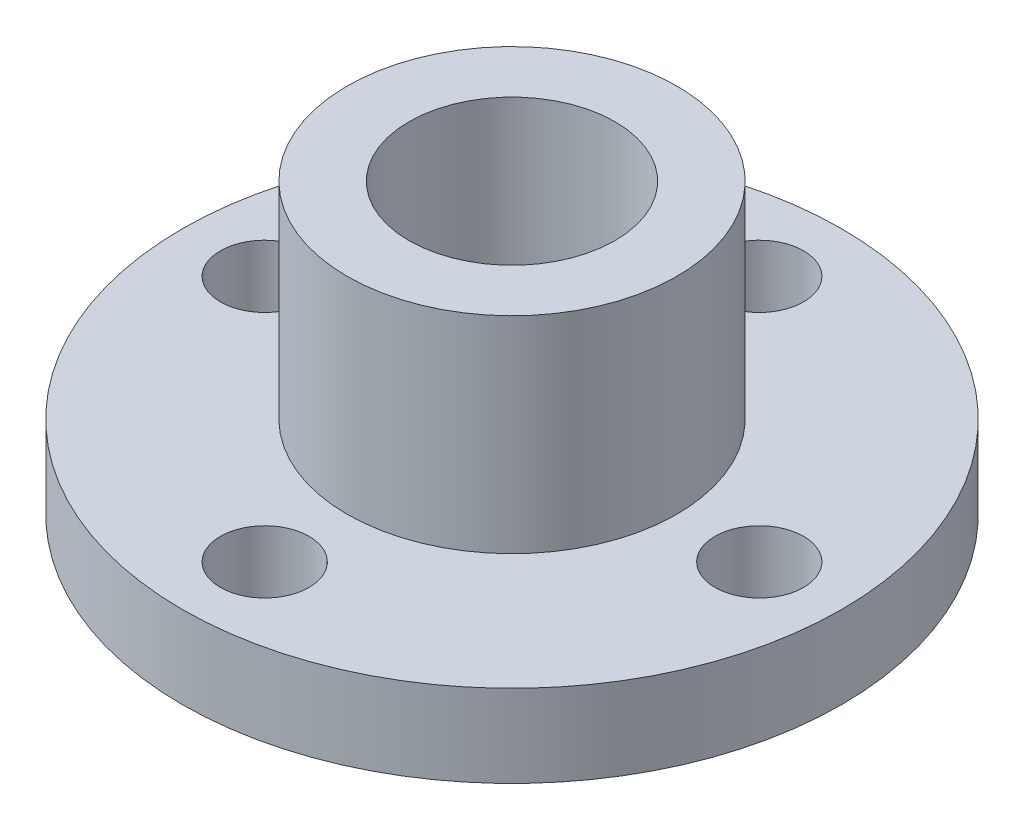
from build123d import *

# Parameters (mm, degrees)
SKETCH2_R          = 2.15
CUT_EXTRUDE1_DEPTH = 5
CIRPATTERN1_COUNT  = 4


with BuildPart() as part:
    # Sketch1 → Revolve4 (revolve)
    with BuildSketch(Plane(origin=(0, 0, 0), x_dir=(0, 0, -1), z_dir=(1, 0, 0))):
        Polygon((8, 0), (8, -10), (16, -10), (16, -14), (5, -14), (5, 0), align=None)
    revolve(axis=Axis((0, 0, 0), (0, -1, 0)))

    # Sketch2 → Cut-Extrude1 (cut, through all)
    with BuildSketch(Plane(origin=(0, -10, 0), x_dir=(1, 0, 0), z_dir=(0, 1, 0))):
        with Locations((-12, 0)):
            Circle(SKETCH2_R)
    cut_extrude1 = extrude(amount=-CUT_EXTRUDE1_DEPTH, mode=Mode.SUBTRACT)

    # CirPattern1: Cut-Extrude1 ×4 about axis
    cirpattern1_axis = Axis((0, 0, 0), (0, 1, 0))
    for i in range(1, CIRPATTERN1_COUNT):
        add(cut_extrude1.rotate(cirpattern1_axis, i * 360 / CIRPATTERN1_COUNT), mode=Mode.SUBTRACT)


solid = part.part
